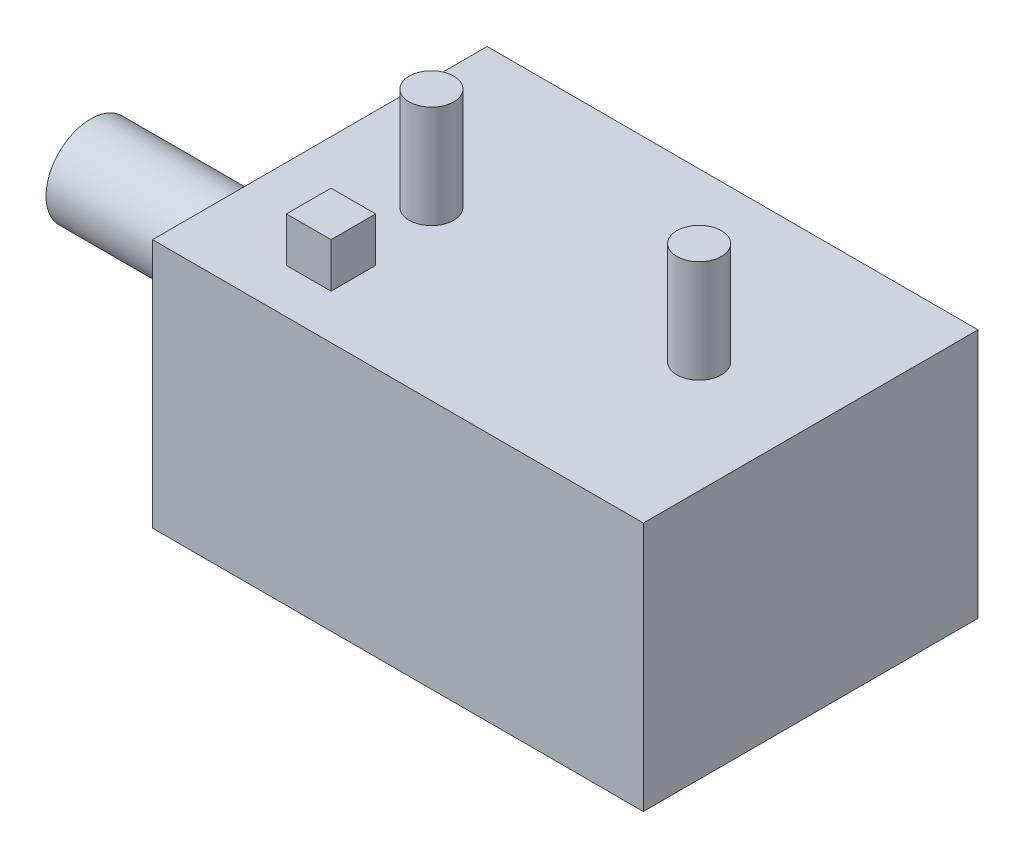
from build123d import *

# Parameters (mm, degrees)
SKETCH2_W           = 110
SKETCH2_H           = 75
BASE_DEPTH          = 56
SKETCH3_R           = 5
HV_CONNECTORS_DEPTH = 23
SKETCH4_R           = 10
LV_CONNECTOR_DEPTH  = 51.38
SKETCH5_W           = 10
SKETCH5_H           = 10
HV_CONNECTOR_DEPTH  = 10


with BuildPart() as part:
    # Sketch2 → Base (new body)
    with BuildSketch(Plane(origin=(0, 0, 0), x_dir=(1, 0, 0), z_dir=(0, 1, 0))):
        Rectangle(SKETCH2_W, SKETCH2_H)
    extrude(amount=BASE_DEPTH)

    # Sketch3 → HV- Connectors (add)
    with BuildSketch(Plane(origin=(0, 56, 0), x_dir=(1, 0, 0), z_dir=(0, 1, 0))):
        with Locations((30, 0)):
            Circle(SKETCH3_R)
        with Locations((-30, 0)):
            Circle(SKETCH3_R)
    extrude(amount=HV_CONNECTORS_DEPTH)

    # Sketch4 → LV Connector (add)
    with BuildSketch(Plane.ZY.offset(55)):
        with Locations((0, 25)):
            Circle(SKETCH4_R)
    extrude(amount=LV_CONNECTOR_DEPTH)

    # Sketch5 → HV+ Connector (add)
    with BuildSketch(Plane(origin=(0, 56, 0), x_dir=(1, 0, 0), z_dir=(0, 1, 0))):
        with Locations((-30, -22.5)):
            Rectangle(SKETCH5_W, SKETCH5_H)
    extrude(amount=HV_CONNECTOR_DEPTH)


solid = part.part
